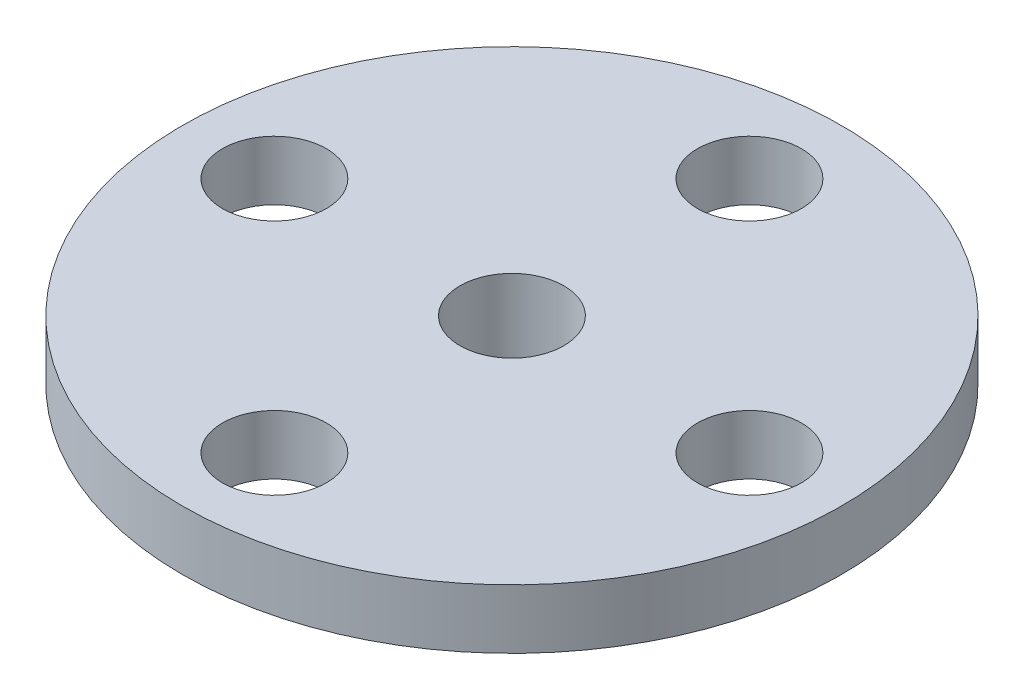
from build123d import *

# Parameters (mm, degrees)
SKETCH1_R          = 11.1
EXTRUDE1_DEPTH     = 2
SKETCH2_R          = 1.75
CUT_EXTRUDE1_DEPTH = 3
SKETCH3_R          = 4.4
EXTRUDE2_DEPTH     = 4.2
SKETCH4_R          = 2.85
CUT_EXTRUDE2_DEPTH = 3
SKETCH5_R          = 1.75
CUT_EXTRUDE3_DEPTH = 4.2


with BuildPart() as part:
    # Sketch1 → Extrude1 (new body)
    with BuildSketch(Plane(origin=(0, 0, 0), x_dir=(1, 0, 0), z_dir=(0, 1, 0))):
        Circle(SKETCH1_R)
    extrude(amount=EXTRUDE1_DEPTH)

    # Sketch2 → Cut-Extrude1 (cut, through all)
    with BuildSketch(Plane(origin=(0, 2, 0), x_dir=(1, 0, 0), z_dir=(0, 1, 0))):
        with Locations((0, 8)):
            Circle(SKETCH2_R)
        with Locations((8, 0)):
            Circle(SKETCH2_R)
        with Locations((0, -8)):
            Circle(SKETCH2_R)
        with Locations((-8, 0)):
            Circle(SKETCH2_R)
    extrude(amount=-CUT_EXTRUDE1_DEPTH, mode=Mode.SUBTRACT)

    # Sketch3 → Extrude2 (add)
    with BuildSketch(Plane.XZ):
        Circle(SKETCH3_R)
    extrude(amount=EXTRUDE2_DEPTH)

    # Sketch4 → Cut-Extrude2 (cut)
    with BuildSketch(Plane.XZ.offset(4.2)):
        Circle(SKETCH4_R)
    extrude(amount=-CUT_EXTRUDE2_DEPTH, mode=Mode.SUBTRACT)

    # Sketch5 → Cut-Extrude3 (cut, through all)
    with BuildSketch(Plane.XZ.offset(1.2)):
        Circle(SKETCH5_R)
    extrude(amount=-CUT_EXTRUDE3_DEPTH, mode=Mode.SUBTRACT)


solid = part.part
